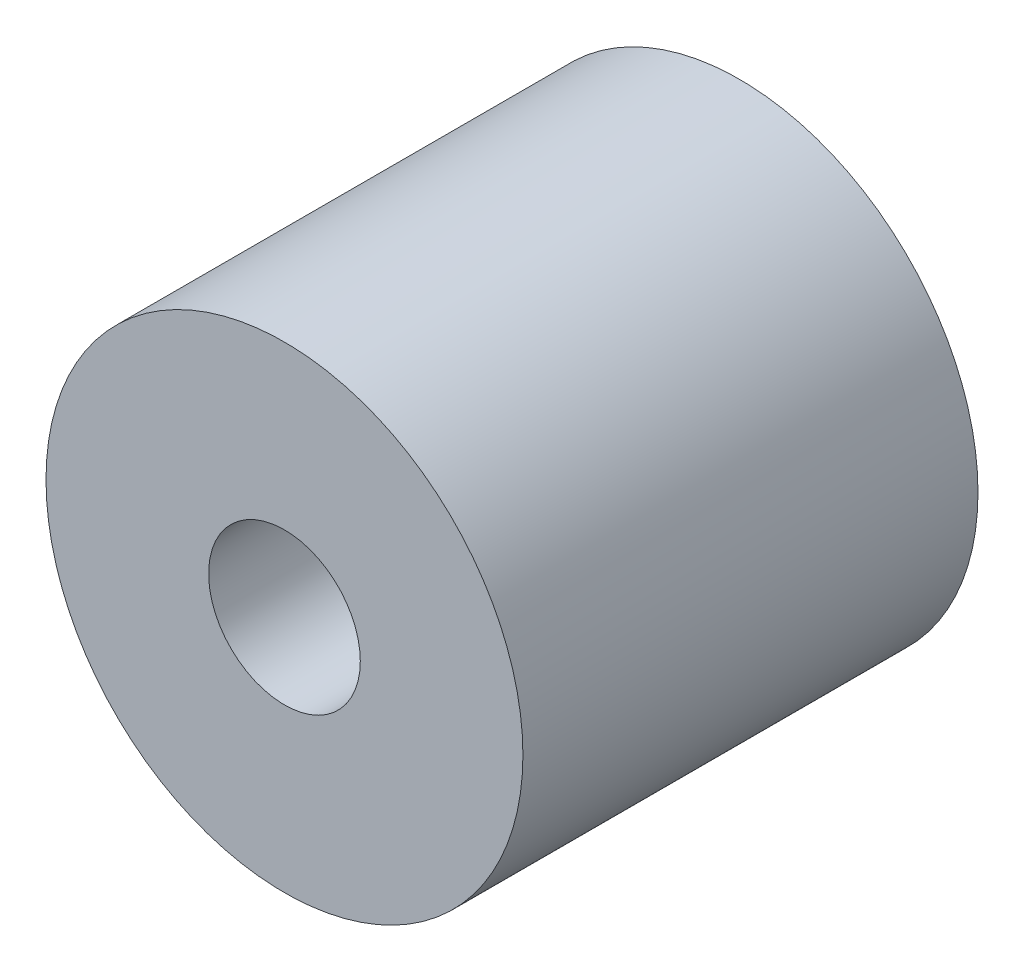
from build123d import *

# Parameters (mm, degrees)
SKETCH1_R           = 4.9911
SKETCH1_R_2         = 1.5875
BOSS_EXTRUDE1_DEPTH = 9.525


with BuildPart() as part:
    # Sketch1 → Boss-Extrude1 (new body)
    with BuildSketch(Plane.XY):
        Circle(SKETCH1_R)
        Circle(SKETCH1_R_2, mode=Mode.SUBTRACT)
    extrude(amount=BOSS_EXTRUDE1_DEPTH)


solid = part.part
